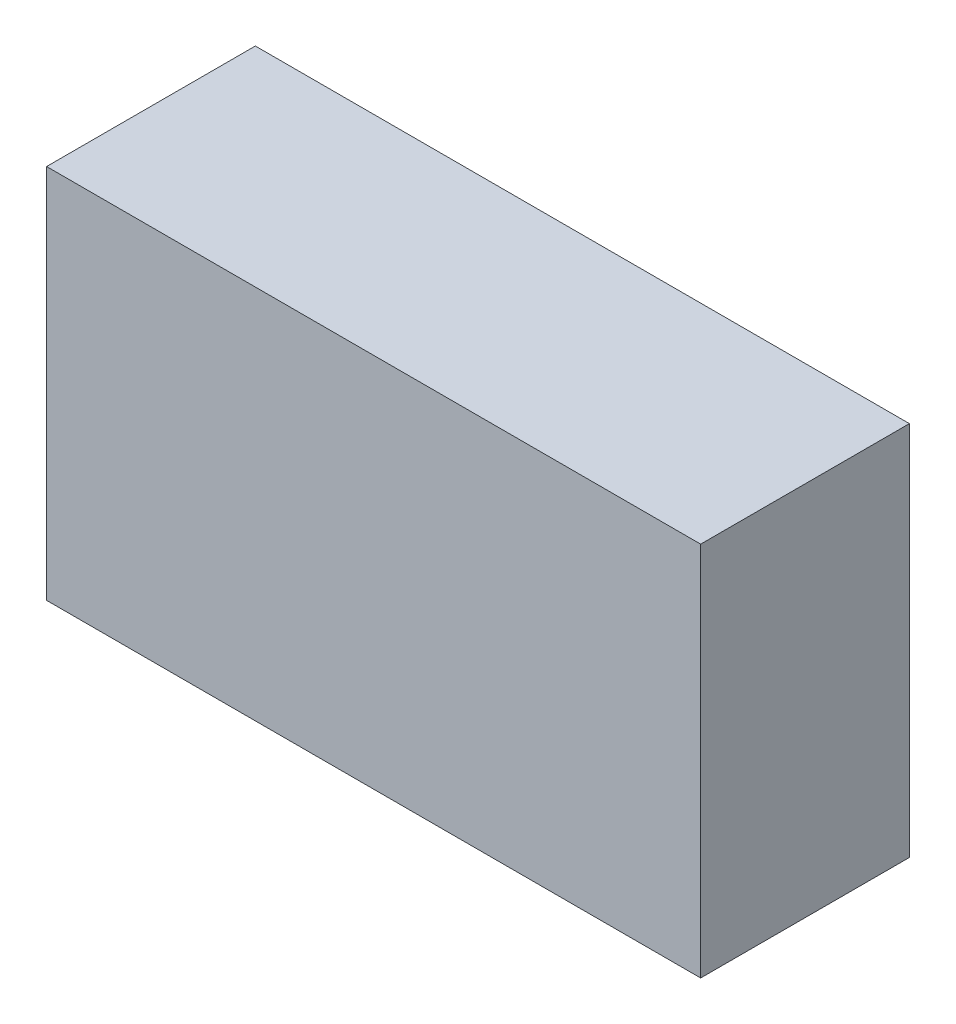
from build123d import *

# Parameters (mm, degrees)
SKETCH_1_W      = 47
SKETCH_1_H      = 27
EXTRUDE_1_DEPTH = 7.5


with BuildPart() as part:
    # Эскиз1 → Бобышка-Вытянуть1 (new body, symmetric)
    with BuildSketch(Plane.XY):
        Rectangle(SKETCH_1_W, SKETCH_1_H)
    extrude(amount=EXTRUDE_1_DEPTH, both=True)


solid = part.part
